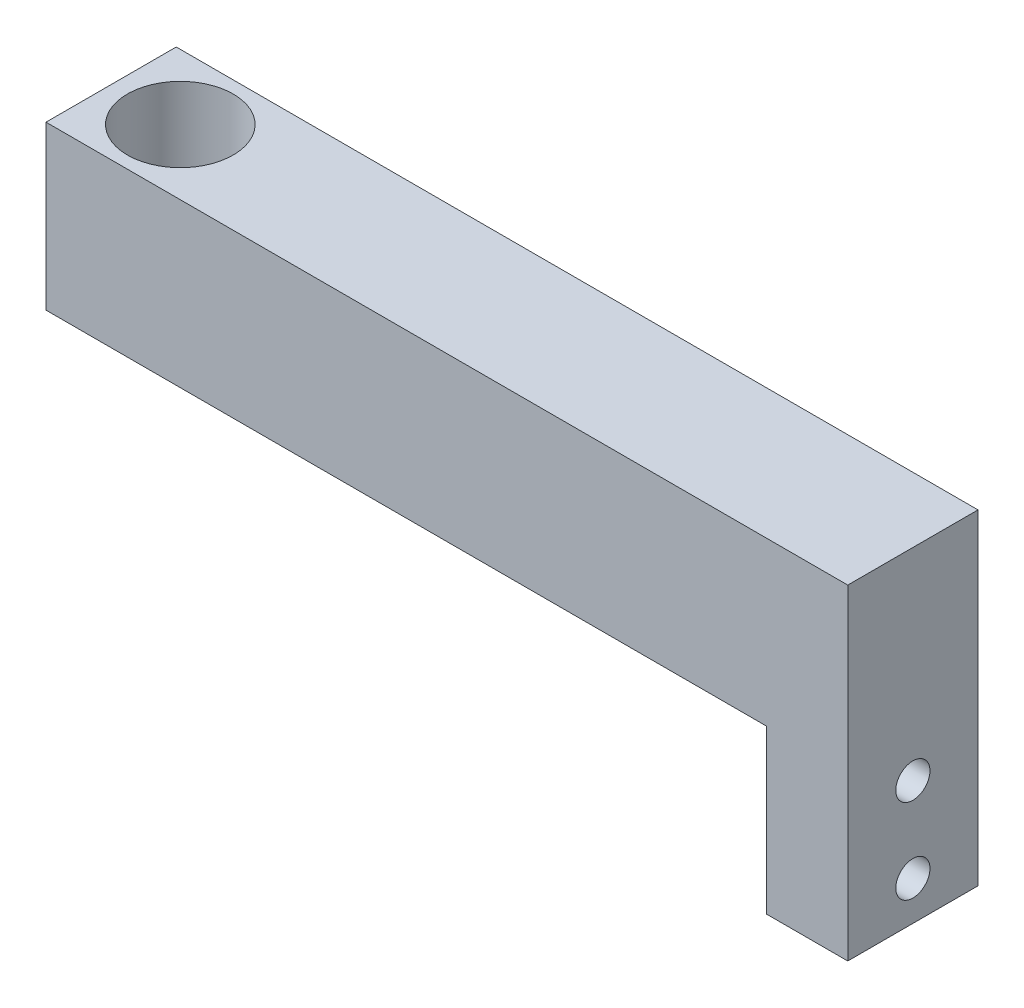
from build123d import *

# Parameters (mm, degrees)
SKETCH_1_W          = 88.5
SKETCH_1_H          = 16
SKETCH_1_R          = 6.5
EXTRUDE_1_DEPTH     = 20
SKETCH_2_W          = 16
SKETCH_2_H          = 40
EXTRUDE_2_DEPTH     = 10
SKETCH_3_R          = 2.1
CUT_EXTRUDE_1_DEPTH = 10


with BuildPart() as part:
    # 草图1 → 凸台-拉伸1 (new body)
    with BuildSketch(Plane(origin=(0, 0, 0), x_dir=(1, 0, 0), z_dir=(0, 1, 0))):
        with Locations((35.75, 0)):
            Rectangle(SKETCH_1_W, SKETCH_1_H)
        Circle(SKETCH_1_R, mode=Mode.SUBTRACT)
    extrude(amount=EXTRUDE_1_DEPTH)

    # 草图2 → 凸台-拉伸2 (add)
    with BuildSketch(Plane(origin=(80, 0, 0), x_dir=(0, 0, -1), z_dir=(1, 0, 0))):
        Rectangle(SKETCH_2_W, SKETCH_2_H)
    extrude(amount=EXTRUDE_2_DEPTH)

    # 草图3 → 切除-拉伸1 (cut)
    with BuildSketch(Plane.ZY.offset(-80)):
        with Locations((0, -4.8)):
            Circle(SKETCH_3_R)
        with Locations((0, -15.2)):
            Circle(SKETCH_3_R)
    extrude(amount=-CUT_EXTRUDE_1_DEPTH, mode=Mode.SUBTRACT)


solid = part.part
